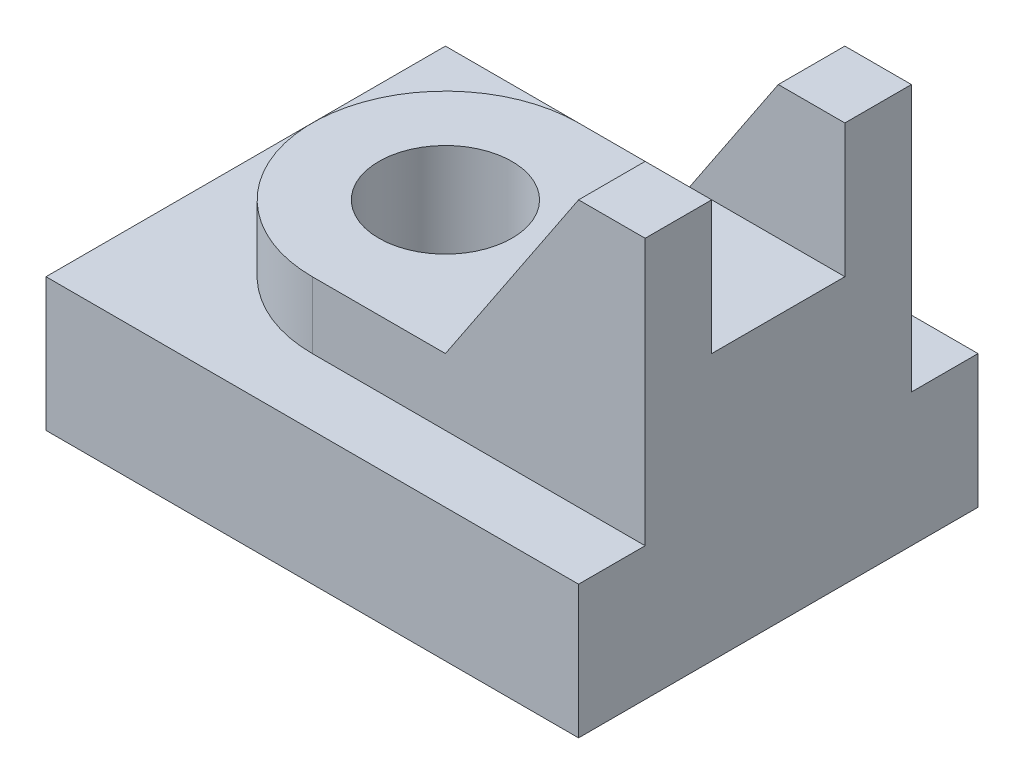
from build123d import *

# Parameters (mm, degrees)
ESBO_O1_W                = 40
ESBO_O1_H                = 30
RESSALTO_EXTRUS_O1_DEPTH = 10
RESSALTO_EXTRUS_O2_DEPTH = 5
RESSALTO_EXTRUS_O3_DEPTH = 20
ESBO_O4_W                = 10
ESBO_O4_H                = 10
CORTE_EXTRUS_O1_DEPTH    = 41
ESBO_O5_R                = 5
CORTE_EXTRUS_O2_DEPTH    = 16


with BuildPart() as part:
    # Esboço1 → Ressalto-extrusão1 (new body)
    with BuildSketch(Plane(origin=(0, 0, 0), x_dir=(1, 0, 0), z_dir=(0, 1, 0))):
        Rectangle(ESBO_O1_W, ESBO_O1_H)
    extrude(amount=RESSALTO_EXTRUS_O1_DEPTH)

    # Esboço2 → Ressalto-extrusão2 (add)
    with BuildSketch(Plane(origin=(0, 10, 0), x_dir=(1, 0, 0), z_dir=(0, 1, 0))):
        with BuildLine():
            Line((20, 10), (20, -10))
            Line((20, -10), (-5, -10))
            ThreePointArc((-5, -10), (-15, 0), (-5, 10))
            Line((-5, 10), (20, 10))
        make_face()
    extrude(amount=RESSALTO_EXTRUS_O2_DEPTH)

    # Esboço3 → Ressalto-extrusão3 (add)
    with BuildSketch(Plane.XY.offset(10)):
        Polygon((20, 15), (5, 15), (15, 30), (20, 30), align=None)
    extrude(amount=-RESSALTO_EXTRUS_O3_DEPTH)

    # Esboço4 → Corte-extrusão1 (cut, through all)
    with BuildSketch(Plane(origin=(20, 0, 0), x_dir=(0, 0, -1), z_dir=(1, 0, 0))):
        with Locations((0, 25)):
            Rectangle(ESBO_O4_W, ESBO_O4_H)
    extrude(amount=-CORTE_EXTRUS_O1_DEPTH, mode=Mode.SUBTRACT)

    # Esboço5 → Corte-extrusão2 (cut, through all)
    with BuildSketch(Plane(origin=(0, 15, 0), x_dir=(1, 0, 0), z_dir=(0, 1, 0))):
        with Locations((-5, 0)):
            Circle(ESBO_O5_R)
    extrude(amount=-CORTE_EXTRUS_O2_DEPTH, mode=Mode.SUBTRACT)


solid = part.part
